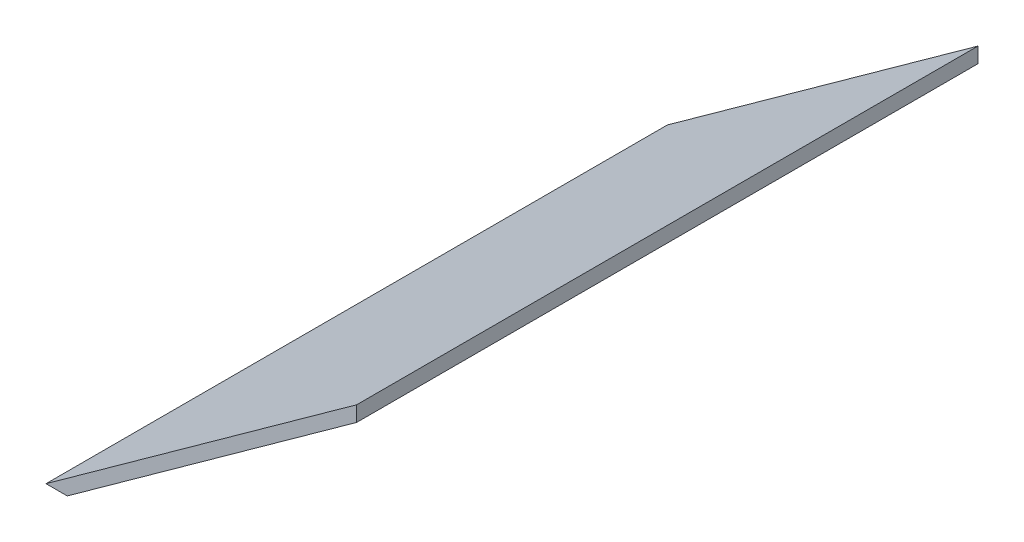
from build123d import *

# Parameters (mm, degrees)
BOSS_EXTRUDE1_DEPTH = 500


with BuildPart() as part:
    # Sketch2 → Boss-Extrude1 (new body)
    with BuildSketch(Plane.XY):
        Polygon((-125, 0), (125, 180), (125, 167.677662559), (5.843047258, 81.884656585), (-107.885642444, 0), align=None)
    extrude(amount=BOSS_EXTRUDE1_DEPTH)


solid = part.part
